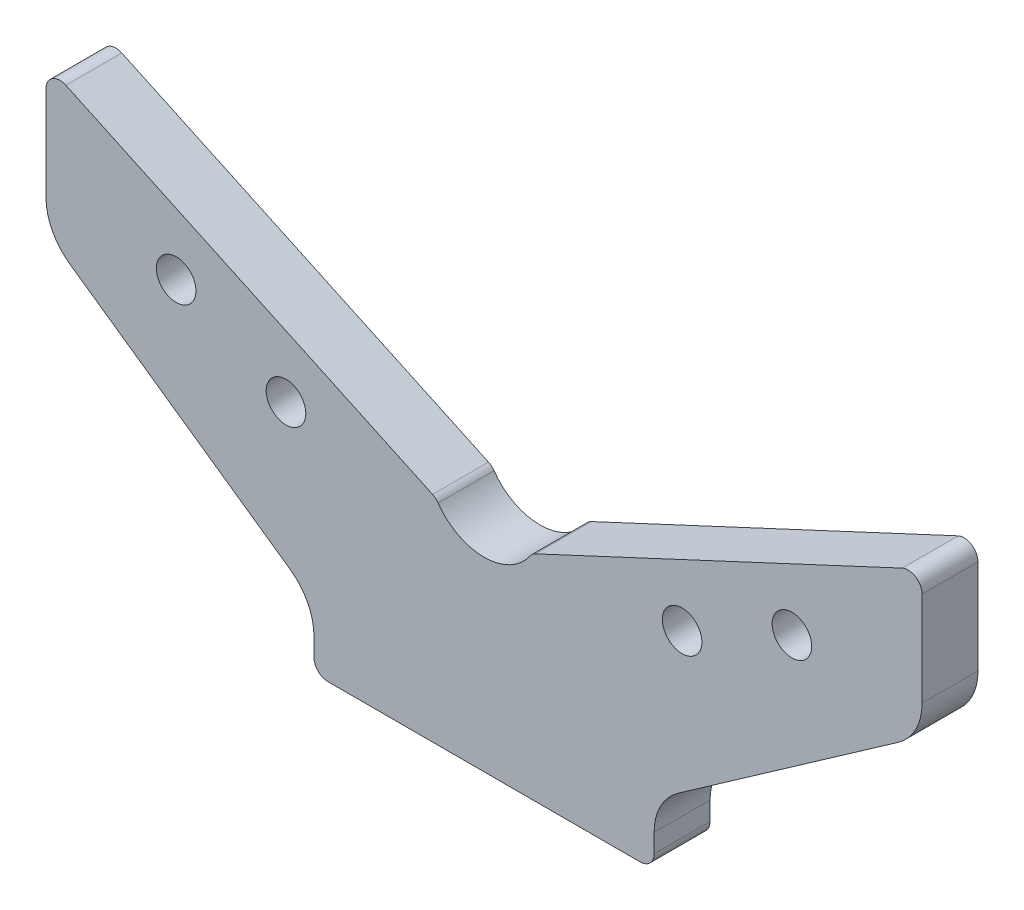
from build123d import *

# Parameters (mm, degrees)
EXTRUDE1_DEPTH         = 12
M10_GEVINDHULLER_D     = 8.5
M10_GEVINDHULLER_DEPTH = 22
M10_GEVINDHULLER_TIP   = 2.553657631


with BuildPart() as part:
    # Sketch1 → Extrude1 (new body)
    with BuildSketch(Plane.XY):
        with BuildLine():
            Line((36.5, 6.991261946), (36.5, 3))
            ThreePointArc((36.5, 3), (35.621320344, 0.878679656), (33.5, 0))
            Line((33.5, 0), (0, 0))
            Line((0, 0), (-33.5, 0))
            ThreePointArc((-33.5, 0), (-35.621320344, 0.878679656), (-36.5, 3))
            Line((-36.5, 3), (-36.5, 6.991261946))
            ThreePointArc((-36.5, 6.991261946), (-37.855870002, 12.532245305), (-41.617082764, 16.821086478))
            Line((-41.617082764, 16.821086478), (-88.882917236, 49.916980075))
            ThreePointArc((-88.882917236, 49.916980075), (-92.644129998, 54.205821248), (-94, 59.746804607))
            Line((-94, 59.746804607), (-94, 80))
            ThreePointArc((-94, 80), (-92.611898825, 82.530174337), (-89.732145215, 82.718923361))
            Line((-89.732145215, 82.718923361), (-11.04340479, 46.02576109))
            ThreePointArc((-11.04340479, 46.02576109), (-10.379689702, 45.602276211), (-9.84900766, 45.020697556))
            ThreePointArc((-9.84900766, 45.020697556), (0, 39.876136865), (9.84900766, 45.020697556))
            ThreePointArc((9.84900766, 45.020697556), (10.379689702, 45.602276211), (11.04340479, 46.02576109))
            Line((11.04340479, 46.02576109), (89.732145215, 82.718923361))
            ThreePointArc((89.732145215, 82.718923361), (92.611898825, 82.530174337), (94, 80))
            Line((94, 80), (94, 59.746804607))
            ThreePointArc((94, 59.746804607), (92.644129998, 54.205821248), (88.882917236, 49.916980075))
            Line((88.882917236, 49.916980075), (41.617082764, 16.821086478))
            ThreePointArc((41.617082764, 16.821086478), (37.855870002, 12.532245305), (36.5, 6.991261946))
        make_face()
    extrude(amount=EXTRUDE1_DEPTH)

    # M10 gevindhuller
    with Locations(Plane.XY.offset(12)):
        with Locations((-66.064002463, 58.441752114), (-42.5, 47.453677309), (66.064002463, 58.441752114), (42.5, 47.453677309)):
            Hole(M10_GEVINDHULLER_D / 2, depth=M10_GEVINDHULLER_DEPTH)
            with Locations((0, 0, -(M10_GEVINDHULLER_DEPTH + M10_GEVINDHULLER_TIP / 2))):  # 118° drill point
                Cone(0, M10_GEVINDHULLER_D / 2, M10_GEVINDHULLER_TIP, mode=Mode.SUBTRACT)


solid = part.part
